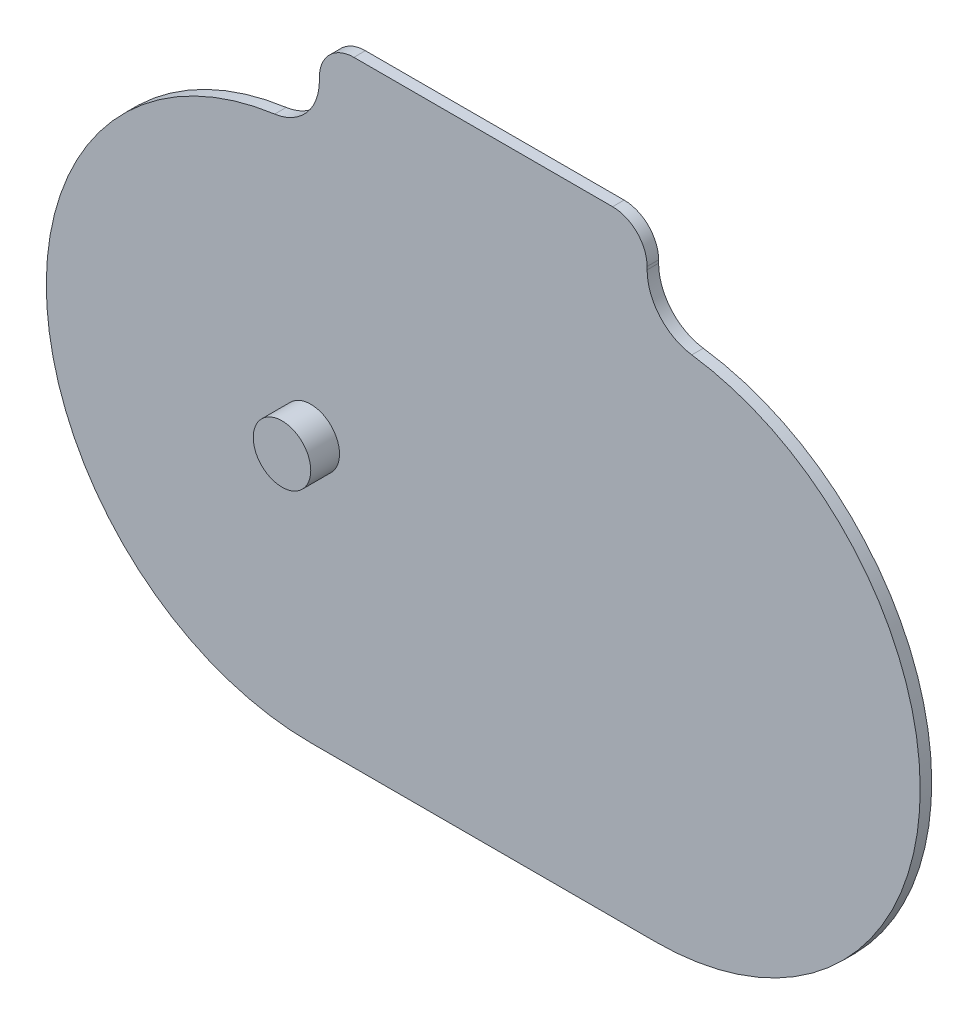
from build123d import *

# Parameters (mm, degrees)
BOSS_EXTRUDE1_DEPTH = 2
SKETCH2_R           = 5
BOSS_EXTRUDE2_DEPTH = 5
SKETCH3_R           = 5
BOSS_EXTRUDE3_DEPTH = 5


with BuildPart() as part:
    # Sketch1 → Boss-Extrude1 (new body)
    with BuildSketch(Plane.XY):
        with BuildLine():
            Line((28.5, 54.486236794), (28.5, 55))
            ThreePointArc((28.5, 55), (26.742640687, 59.242640687), (22.5, 61))
            Line((22.5, 61), (-22.5, 61))
            ThreePointArc((-22.5, 61), (-26.742640687, 59.242640687), (-28.5, 55))
            Line((-28.5, 55), (-28.5, 54.486236794))
            ThreePointArc((-28.5, 54.486236794), (-30.715994747, 48.572078128), (-36.272727273, 45.570307137))
            ThreePointArc((-36.272727273, 45.570307137), (-75.892451058, -3.143713703), (-30, -46))
            Line((-30, -46), (30, -46))
            ThreePointArc((30, -46), (75.892451058, -3.143713703), (36.272727273, 45.570307137))
            ThreePointArc((36.272727273, 45.570307137), (30.715994747, 48.572078128), (28.5, 54.486236794))
        make_face()
    extrude(amount=BOSS_EXTRUDE1_DEPTH)

    # Sketch2 → Boss-Extrude2 (add)
    with BuildSketch(Plane.XY.offset(2)):
        with Locations((-30, 0)):
            Circle(SKETCH2_R)
    extrude(amount=BOSS_EXTRUDE2_DEPTH)

    # Sketch3 → Boss-Extrude3 (add)
    with BuildSketch(Plane(origin=(0, 0, 0), x_dir=(-1, 0, 0), z_dir=(0, 0, -1))):
        with Locations((-30, 0)):
            Circle(SKETCH3_R)
    extrude(amount=BOSS_EXTRUDE3_DEPTH)


solid = part.part
